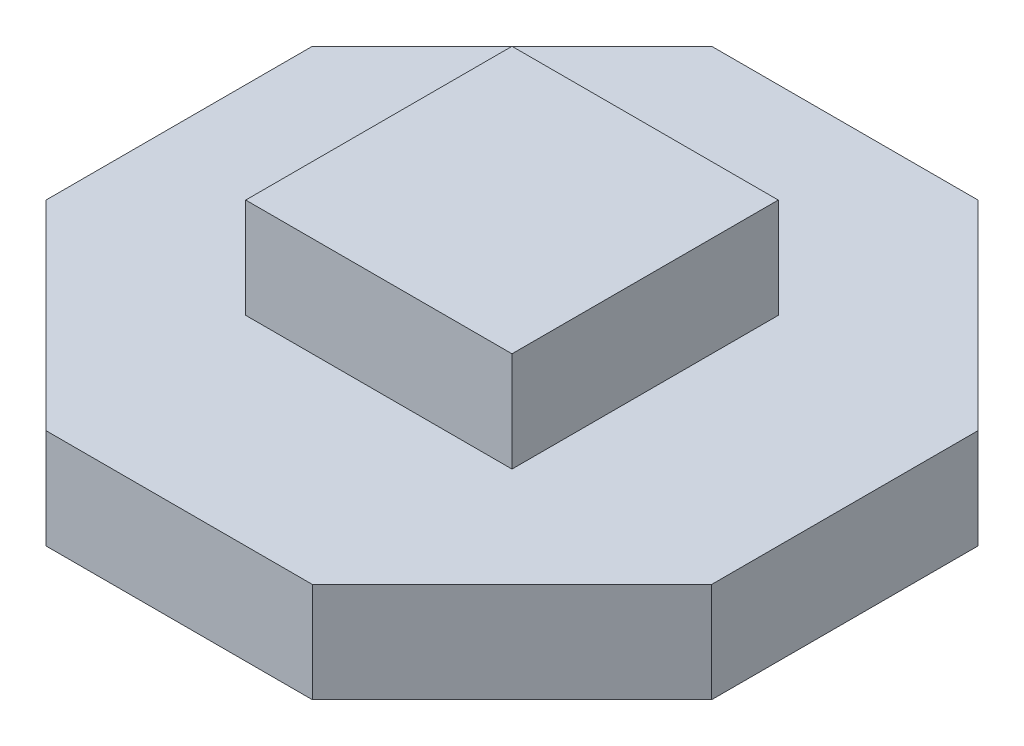
from build123d import *

# Parameters (mm, degrees)
SKETCH1_W           = 10
SKETCH1_H           = 10
BOSS_EXTRUDE1_DEPTH = 1.5
SKETCH2_W           = 4
SKETCH2_H           = 4
BOSS_EXTRUDE2_DEPTH = 1.5
CUT_EXTRUDE1_DEPTH  = 1.5
CIRPATTERN1_COUNT   = 4


with BuildPart() as part:
    # Sketch1 → Boss-Extrude1 (new body)
    with BuildSketch(Plane(origin=(0, 0, 0), x_dir=(1, 0, 0), z_dir=(0, 1, 0))):
        Rectangle(SKETCH1_W, SKETCH1_H)
    extrude(amount=BOSS_EXTRUDE1_DEPTH)

    # Sketch2 → Boss-Extrude2 (add)
    with BuildSketch(Plane(origin=(0, 1.5, 0), x_dir=(1, 0, 0), z_dir=(0, 1, 0))):
        Rectangle(SKETCH2_W, SKETCH2_H)
    extrude(amount=BOSS_EXTRUDE2_DEPTH)

    # Sketch3 → Cut-Extrude1 (cut)
    with BuildSketch(Plane(origin=(0, 1.5, 0), x_dir=(1, 0, 0), z_dir=(0, 1, 0))):
        Polygon((-5, 2), (-2, 5), (-5, 5), align=None)
    cut_extrude1 = extrude(amount=-CUT_EXTRUDE1_DEPTH, mode=Mode.SUBTRACT)

    # CirPattern1: Cut-Extrude1 ×4 about axis
    cirpattern1_axis = Axis((0, 0, 0), (0, 1, 0))
    for i in range(1, CIRPATTERN1_COUNT):
        add(cut_extrude1.rotate(cirpattern1_axis, i * 360 / CIRPATTERN1_COUNT), mode=Mode.SUBTRACT)


solid = part.part
